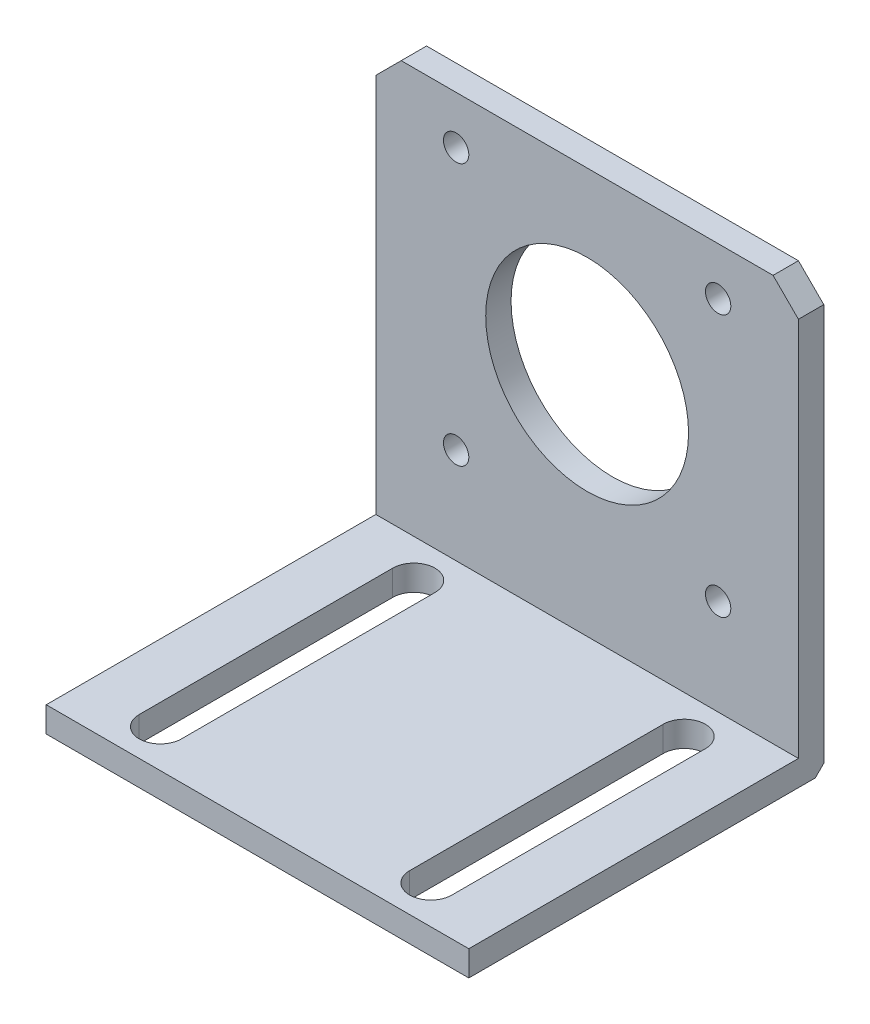
from build123d import *

# Parameters (mm, degrees)
SKETCH1_R           = 12
SKETCH1_R_2         = 1.5
BOSS_EXTRUDE1_DEPTH = 3
BOSS_EXTRUDE2_DEPTH = 3
SKETCH3_W           = 50
SKETCH3_H           = 3
BOSS_EXTRUDE3_DEPTH = 39
CHAMFER1_SIZE       = 1
CUT_EXTRUDE1_DEPTH  = 3


with BuildPart() as part:
    # Sketch1 → Boss-Extrude1 (new body)
    with BuildSketch(Plane.XY):
        Polygon((-22, 21.15), (-25, 18.15), (-25, -23.85), (-22, -26.85), (22, -26.85), (25, -23.85), (25, 18.15), (22, 21.15), align=None)
        Circle(SKETCH1_R, mode=Mode.SUBTRACT)
        with Locations((-15.5, 15.5)):
            Circle(SKETCH1_R_2, mode=Mode.SUBTRACT)
        with Locations((15.5, 15.5)):
            Circle(SKETCH1_R_2, mode=Mode.SUBTRACT)
        with Locations((-15.5, -15.5)):
            Circle(SKETCH1_R_2, mode=Mode.SUBTRACT)
        with Locations((15.5, -15.5)):
            Circle(SKETCH1_R_2, mode=Mode.SUBTRACT)
    extrude(amount=BOSS_EXTRUDE1_DEPTH)

    # Sketch2 → Boss-Extrude2 (add)
    with BuildSketch(Plane(origin=(0, 0, 0), x_dir=(-1, 0, 0), z_dir=(0, 0, -1))):
        Polygon((-25, -23.85), (-25, -29.85), (25, -29.85), (25, -23.85), (22, -26.85), (-22, -26.85), align=None)
    extrude(amount=-BOSS_EXTRUDE2_DEPTH)

    # Sketch3 → Boss-Extrude3 (add)
    with BuildSketch(Plane.XY.offset(3)):
        with Locations((0, -28.35)):
            Rectangle(SKETCH3_W, SKETCH3_H)
    extrude(amount=BOSS_EXTRUDE3_DEPTH)

    # Chamfer1
    chamfer1_edges = [part.edges().sort_by_distance(p)[0] for p in [
        (0, -29.85, 0),
    ]]
    chamfer(chamfer1_edges, length=CHAMFER1_SIZE)

    # Sketch4 → Cut-Extrude1 (cut)
    with BuildSketch(Plane(origin=(0, -26.85, 0), x_dir=(1, 0, 0), z_dir=(0, 1, 0))):
        with BuildLine():
            Line((18.5, -7.5), (18.5, -37.5))
            ThreePointArc((18.5, -37.5), (16, -40), (13.5, -37.5))
            Line((13.5, -37.5), (13.5, -7.5))
            ThreePointArc((13.5, -7.5), (16, -5), (18.5, -7.5))
        make_face()
        with BuildLine():
            Line((-18.5, -7.5), (-18.5, -37.5))
            ThreePointArc((-18.5, -37.5), (-16, -40), (-13.5, -37.5))
            Line((-13.5, -37.5), (-13.5, -7.5))
            ThreePointArc((-13.5, -7.5), (-16, -5), (-18.5, -7.5))
        make_face()
    extrude(amount=-CUT_EXTRUDE1_DEPTH, mode=Mode.SUBTRACT)


solid = part.part
